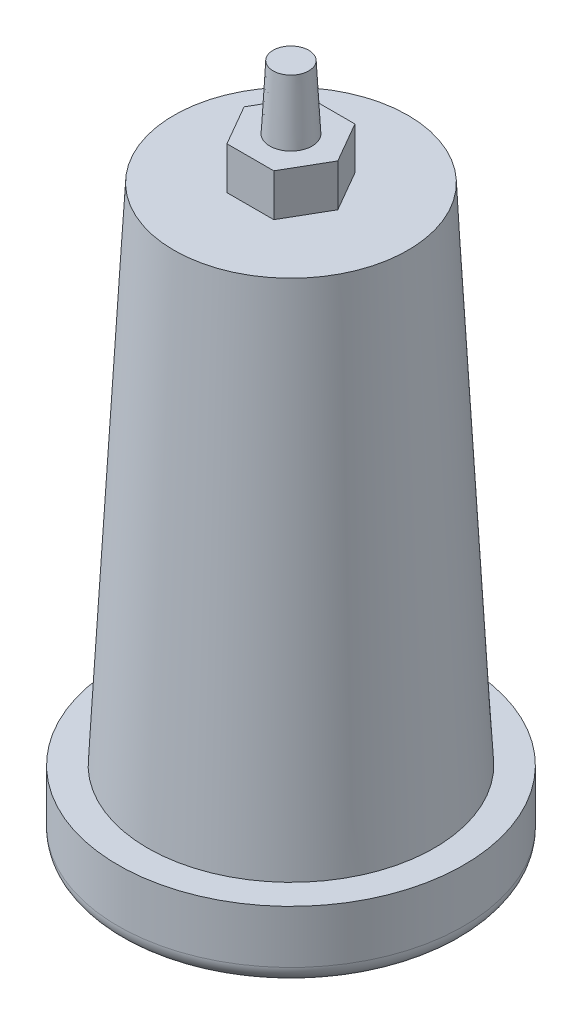
from build123d import *

# Parameters (mm, degrees)
SKETCH1_R           = 40.656565244
BOSS_EXTRUDE2_DEPTH = 143
BOSS_EXTRUDE2_TAPER = 3
SKETCH2_R           = 49
BOSS_EXTRUDE3_DEPTH = 20
FILLET1_R           = 5
BOSS_EXTRUDE4_START = 143
BOSS_EXTRUDE4_DEPTH = 12
BOSS_EXTRUDE5_START = 155
SKETCH4_R           = 6
BOSS_EXTRUDE5_DEPTH = 18
BOSS_EXTRUDE5_TAPER = 3


with BuildPart() as part:
    # Sketch1 → Boss-Extrude2 (new body)
    with BuildSketch(Plane(origin=(0, 0, 0), x_dir=(1, 0, 0), z_dir=(0, 1, 0))):
        Circle(SKETCH1_R)
    extrude(amount=BOSS_EXTRUDE2_DEPTH, taper=BOSS_EXTRUDE2_TAPER)

    # Sketch2 → Boss-Extrude3 (add)
    with BuildSketch(Plane(origin=(0, 0, 0), x_dir=(-1, 0, 0), z_dir=(0, -1, 0))):
        Circle(SKETCH2_R)
    extrude(amount=BOSS_EXTRUDE3_DEPTH)

    # Fillet1
    fillet1_edges = [part.edges().sort_by_distance(p)[0] for p in [
        (49, -20, 0),
    ]]
    fillet(fillet1_edges, radius=FILLET1_R)

    # Sketch3 → Boss-Extrude4 (add)
    with BuildSketch(Plane(origin=(0, 0, 0), x_dir=(1, 0, 0), z_dir=(0, 1, 0)).offset(BOSS_EXTRUDE4_START)):
        Polygon((6.639528096, -11.5), (13.279056191, 0), (6.639528096, 11.5), (-6.639528096, 11.5), (-13.279056191, 0), (-6.639528096, -11.5), align=None)
    extrude(amount=BOSS_EXTRUDE4_DEPTH)

    # Sketch4 → Boss-Extrude5 (add)
    with BuildSketch(Plane(origin=(0, 0, 0), x_dir=(1, 0, 0), z_dir=(0, 1, 0)).offset(BOSS_EXTRUDE5_START)):
        Circle(SKETCH4_R)
    extrude(amount=BOSS_EXTRUDE5_DEPTH, taper=BOSS_EXTRUDE5_TAPER)


solid = part.part
